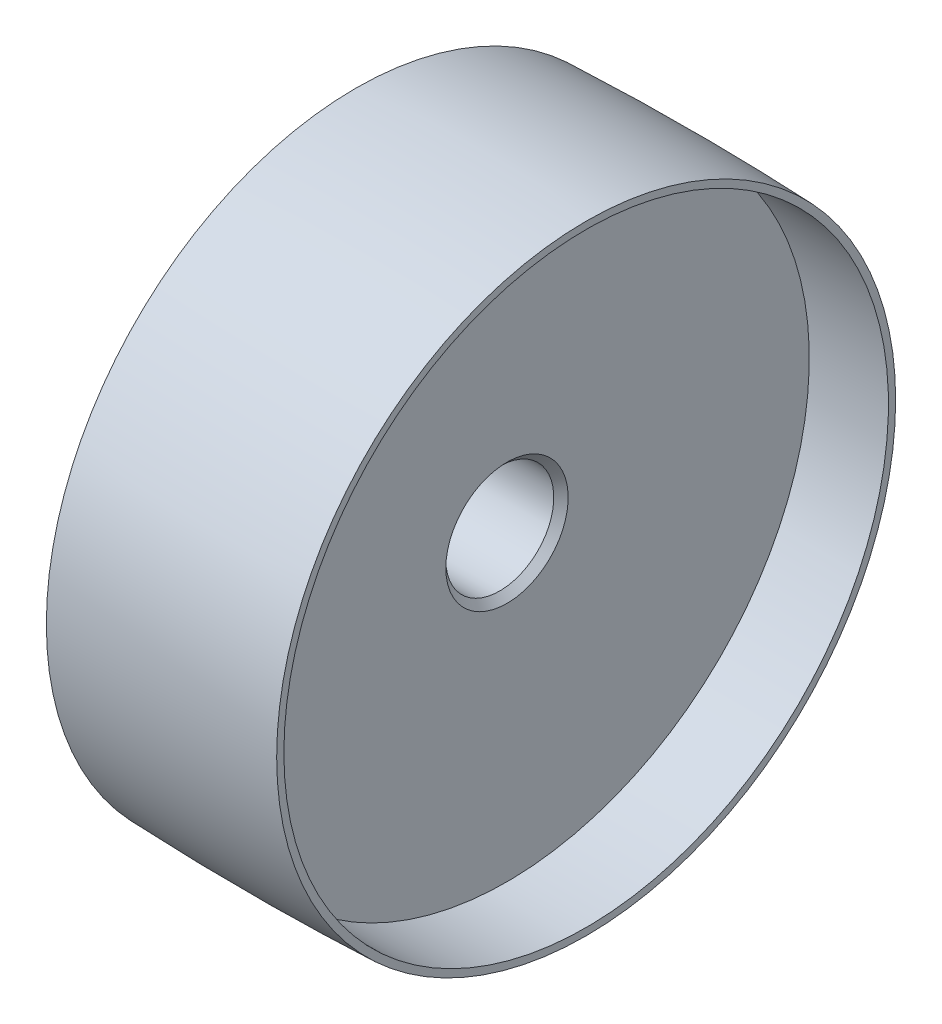
from build123d import *

# Parameters (mm, degrees)
CHAMFER_2_SIZE = 1


with BuildPart() as part:
    # Эскиз1 → Повернуть1 (revolve)
    with BuildSketch(Plane.XY):
        with BuildLine():
            Line((0, 7.5), (0, 15))
            Line((0, 15), (11, 15))
            Line((11, 15), (11, 42))
            Line((11, 42), (0, 42))
            Line((0, 42), (0, 43))
            ThreePointArc((0, 43), (16, 43.3), (32, 43))
            Line((32, 43), (32, 42))
            Line((32, 42), (21, 42))
            Line((21, 42), (21, 7.5))
            Line((21, 7.5), (0, 7.5))
        make_face()
    revolve(axis=Axis((0, 0, 0), (1, 0, 0)))

    # Фаска2
    chamfer_2_edges = [part.edges().sort_by_distance(p)[0] for p in [
        (0, -15, 0),
        (0, -7.5, 0),
        (21, -7.5, 0),
    ]]
    chamfer(chamfer_2_edges, length=CHAMFER_2_SIZE)


solid = part.part
